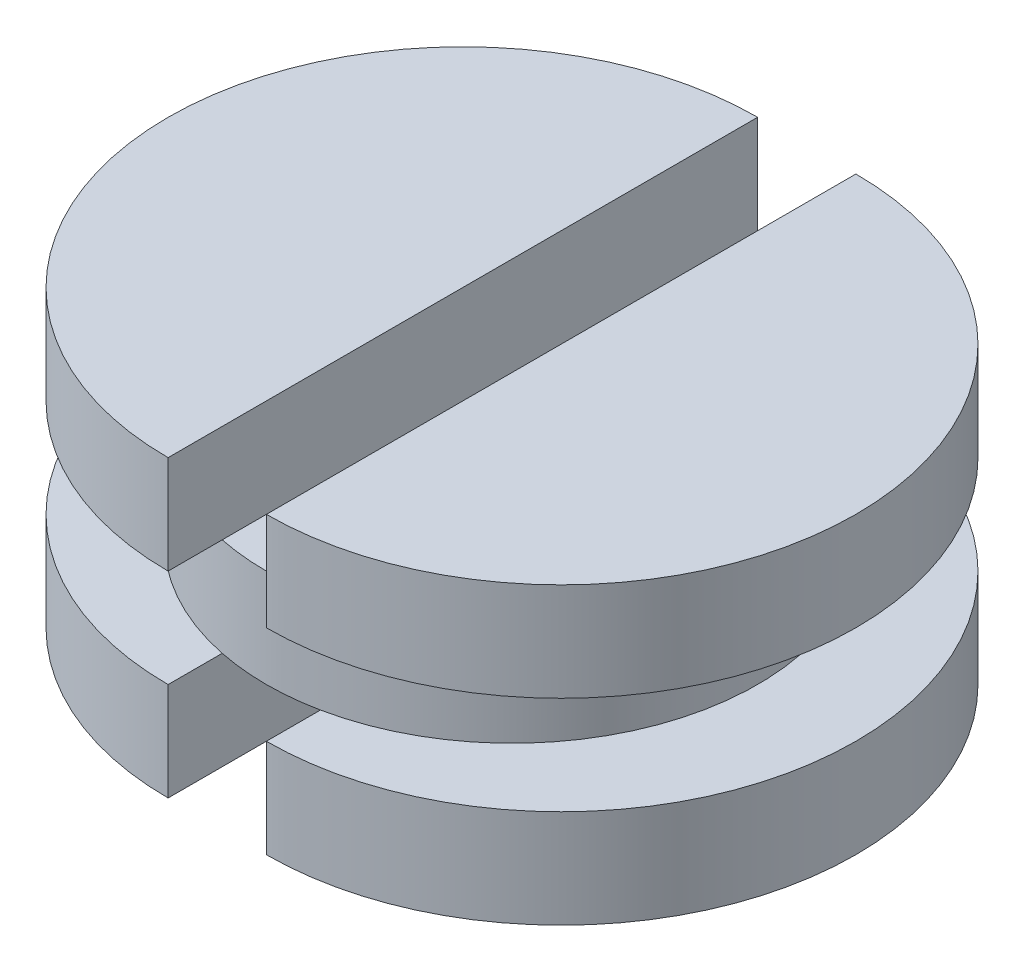
from build123d import *

# Parameters (mm, degrees)
BOSS_EXTRUDE1_DEPTH   = 0.2
BOSS_EXTRUDE1_2_DEPTH = 0.2
SKETCH2_R             = 0.5
BOSS_EXTRUDE2_DEPTH   = 0.2
BOSS_EXTRUDE3_DEPTH   = 0.2


with BuildPart() as part:
    # Sketch1 → Boss-Extrude1 (new body)
    with BuildSketch(Plane(origin=(0, 0, 0), x_dir=(1, 0, 0), z_dir=(0, 1, 0))):
        with BuildLine():
            Line((0.1, -0.6), (0.1, 0.6))
            ThreePointArc((0.1, 0.6), (0.7, 0), (0.1, -0.6))
        make_face()
    extrude(amount=BOSS_EXTRUDE1_DEPTH)



with BuildPart() as body_2:
    # Sketch1 → Boss-Extrude1 2 (new body)
    with BuildSketch(Plane(origin=(0, 0, 0), x_dir=(1, 0, 0), z_dir=(0, 1, 0))):
        with BuildLine():
            Line((-0.1, -0.6), (-0.1, 0.6))
            ThreePointArc((-0.1, 0.6), (-0.7, 0), (-0.1, -0.6))
        make_face()
    extrude(amount=BOSS_EXTRUDE1_2_DEPTH)


with BuildPart() as part_1:
    add(part.part)

    add(body_2.part)  # Boss-Extrude2 merges body 2
    # Sketch2 → Boss-Extrude2 (add)
    with BuildSketch(Plane(origin=(0, 0.2, 0), x_dir=(1, 0, 0), z_dir=(0, 1, 0))):
        Circle(SKETCH2_R)
    extrude(amount=BOSS_EXTRUDE2_DEPTH)

    # Sketch3 → Boss-Extrude3 (add)
    with BuildSketch(Plane(origin=(0, 0.4, 0), x_dir=(1, 0, 0), z_dir=(0, 1, 0))):
        with BuildLine():
            Line((-0.1, -0.6), (-0.1, 0.6))
            ThreePointArc((-0.1, 0.6), (-0.7, 0), (-0.1, -0.6))
        make_face()
        with BuildLine():
            Line((0.1, 0.6), (0.1, -0.6))
            ThreePointArc((0.1, -0.6), (0.7, 0), (0.1, 0.6))
        make_face()
    extrude(amount=BOSS_EXTRUDE3_DEPTH)


solid = part_1.part
